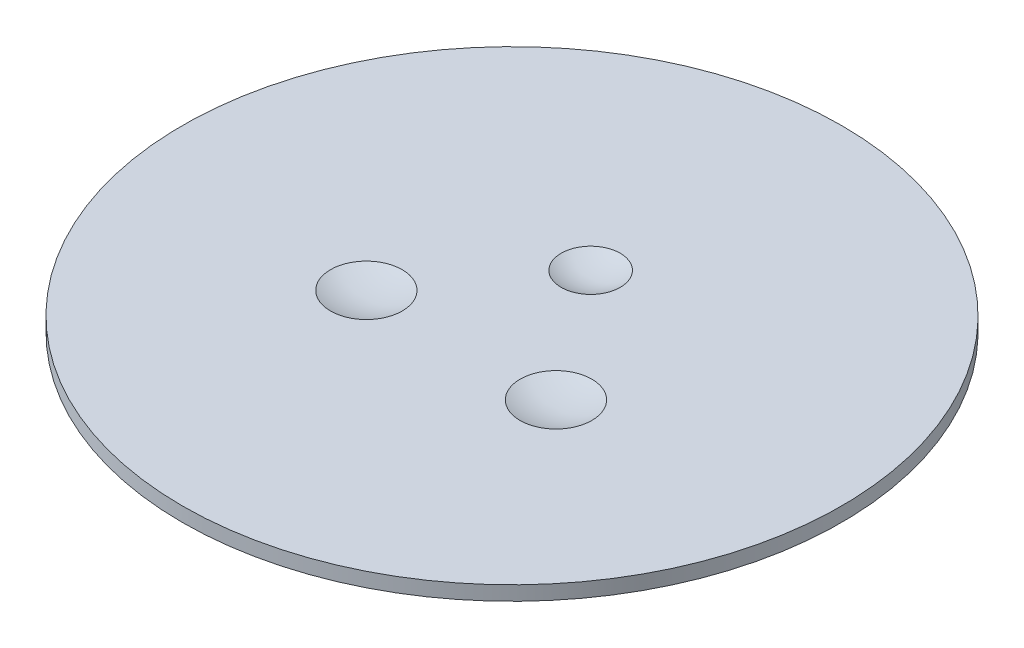
from build123d import *

# Parameters (mm, degrees)
SKETCH1_R           = 1150
BOSS_EXTRUDE1_DEPTH = 50


with BuildPart() as part:
    # Sketch1 → Boss-Extrude1 (new body)
    with BuildSketch(Plane(origin=(0, 0, 0), x_dir=(1, 0, 0), z_dir=(0, 1, 0))):
        Circle(SKETCH1_R)
    extrude(amount=BOSS_EXTRUDE1_DEPTH)

    # Sketch3 → Cut-Revolve2 (revolve, cut)
    with BuildSketch(Plane.XY.offset(177.391142296)):
        with BuildLine():
            ThreePointArc((-330.835, 25.4), (-267.105415034, 31.608364305), (-205.772295727, 50))
            Line((-205.772295727, 50), (-330.835, 50))
            Line((-330.835, 50), (-330.835, 25.4))
        make_face()
    revolve(axis=Axis((-330.835, 25.4, 177.391142296), (0, 1, 0)), mode=Mode.SUBTRACT)

    # Sketch3_4 → Cut-Revolve3 (revolve, cut)
    with BuildSketch(Plane.XY.offset(177.391142296)):
        with BuildLine():
            Line((330.835, 50), (330.835, 25.4))
            ThreePointArc((330.835, 25.4), (267.105415034, 31.608364305), (205.772295727, 50))
            Line((205.772295727, 50), (330.835, 50))
        make_face()
    revolve(axis=Axis((330.835, 50, 177.391142296), (0, -1, 0)), mode=Mode.SUBTRACT)

    # Sketch6 → Cut-Revolve4 (revolve, cut)
    with BuildSketch(Plane.XY.offset(-274.523238616)):
        with BuildLine():
            ThreePointArc((0, 25.4), (53.026219929, 31.635029737), (103.159875921, 50))
            Line((103.159875921, 50), (0, 50))
            Line((0, 50), (0, 25.4))
        make_face()
    revolve(axis=Axis((0, 25.4, -274.523238616), (0, 1, 0)), mode=Mode.SUBTRACT)


solid = part.part
